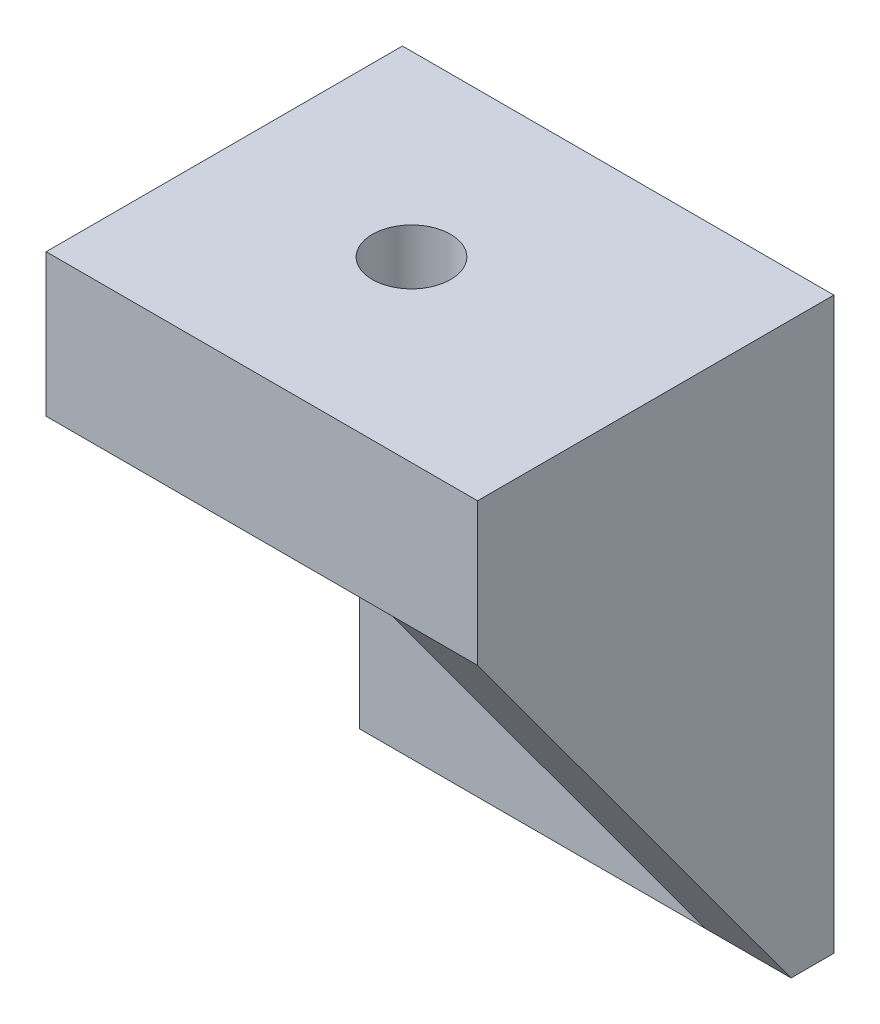
from build123d import *

# Parameters (mm, degrees)
SKETCH1_W           = 15.135
SKETCH1_H           = 12.5
BASE_DEPTH          = 5
SKETCH2_W           = 15.135
SKETCH2_H           = 15
BOSS_EXTRUDE2_DEPTH = 1.5
BOSS_EXTRUDE3_DEPTH = 15.135
SKETCH4_W           = 9.135
SKETCH4_H           = 15
CUT_EXTRUDE1_DEPTH  = 11
SKETCH5_R           = 1.375
CUT_EXTRUDE2_DEPTH  = 2
SKETCH6_R           = 1.375
CUT_EXTRUDE3_DEPTH  = 5.75
CUT_EXTRUDE4_DEPTH  = 25.485172511


with BuildPart() as part:
    # Sketch1 → base (new body)
    with BuildSketch(Plane(origin=(0, 0, 0), x_dir=(1, 0, 0), z_dir=(0, 1, 0))):
        with Locations((7.5675, 6.25)):
            Rectangle(SKETCH1_W, SKETCH1_H)
    extrude(amount=BASE_DEPTH)

    # Sketch2 → Boss-Extrude2 (add)
    with BuildSketch(Plane(origin=(0, 0, -12.5), x_dir=(-1, 0, 0), z_dir=(0, 0, -1))):
        with Locations((-7.5675, -7.5)):
            Rectangle(SKETCH2_W, SKETCH2_H)
    extrude(amount=-BOSS_EXTRUDE2_DEPTH)

    # Sketch3 → Boss-Extrude3 (add)
    with BuildSketch(Plane.ZY):
        Polygon((0, 0), (-11, -15), (-11, 0), align=None)
    extrude(amount=-BOSS_EXTRUDE3_DEPTH)

    # Sketch4 → Cut-Extrude1 (cut)
    with BuildSketch(Plane.XY):
        with Locations((7.5675, -7.5)):
            Rectangle(SKETCH4_W, SKETCH4_H)
    extrude(amount=-CUT_EXTRUDE1_DEPTH, mode=Mode.SUBTRACT)

    # Sketch5 → Cut-Extrude2 (cut)
    with BuildSketch(Plane.XY.offset(-11)):
        with Locations((7.5675, -4)):
            Circle(SKETCH5_R)
        with Locations((7.5675, -11)):
            Circle(SKETCH5_R)
    extrude(amount=-CUT_EXTRUDE2_DEPTH, mode=Mode.SUBTRACT)

    # Sketch6 → Cut-Extrude3 (cut)
    with BuildSketch(Plane(origin=(0, 5, 0), x_dir=(1, 0, 0), z_dir=(0, 1, 0))):
        with Locations((6.5675, 6.25)):
            Circle(SKETCH6_R)
    extrude(amount=-CUT_EXTRUDE3_DEPTH, mode=Mode.SUBTRACT)

    # Sketch7 → Cut-Extrude4 (cut)
    with BuildSketch(Plane.ZY.offset(-12.135)):
        Polygon((-11, -15), (0, 0), (-11, 0), align=None)
    extrude(amount=CUT_EXTRUDE4_DEPTH, mode=Mode.SUBTRACT)


solid = part.part
